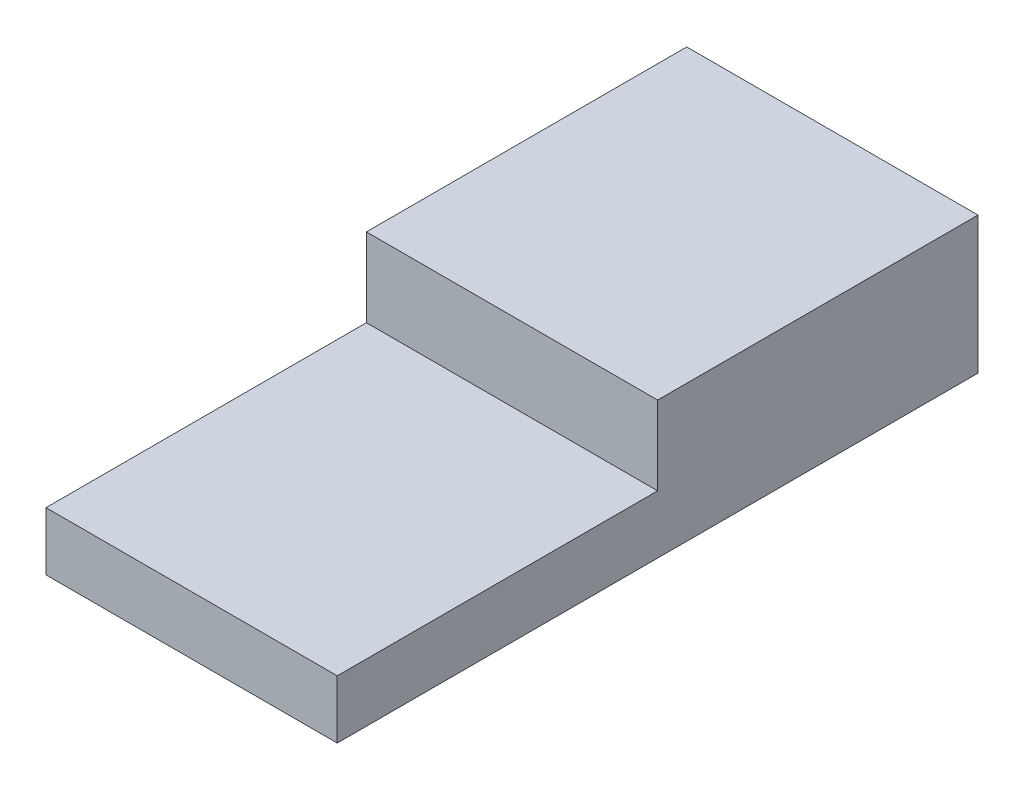
from build123d import *

# Parameters (mm, degrees)
SKETCH3_W           = 10
SKETCH3_H           = 22
BOSS_EXTRUDE1_DEPTH = 2
SKETCH4_W           = 10
SKETCH4_H           = 11
BOSS_EXTRUDE2_DEPTH = 2.7
SKETCH5_R           = 1
CUT_EXTRUDE1_DEPTH  = 2


with BuildPart() as part:
    # Sketch3 → Boss-Extrude1 (new body)
    with BuildSketch(Plane(origin=(0, 0, 0), x_dir=(1, 0, 0), z_dir=(0, 1, 0))):
        with Locations((-12.849765258, -8.469483568)):
            Rectangle(SKETCH3_W, SKETCH3_H)
    extrude(amount=BOSS_EXTRUDE1_DEPTH)

    # Sketch4 → Boss-Extrude2 (add)
    with BuildSketch(Plane(origin=(0, 2, 0), x_dir=(1, 0, 0), z_dir=(0, 1, 0))):
        with Locations((-12.849765258, -2.969483568)):
            Rectangle(SKETCH4_W, SKETCH4_H)
    extrude(amount=BOSS_EXTRUDE2_DEPTH)

    # Sketch5 → Cut-Extrude1 (cut)
    with BuildSketch(Plane.ZY.offset(17.849765258)):
        with Locations((3.369483568, 2.3)):
            Circle(SKETCH5_R)
    extrude(amount=-CUT_EXTRUDE1_DEPTH, mode=Mode.SUBTRACT)


solid = part.part
